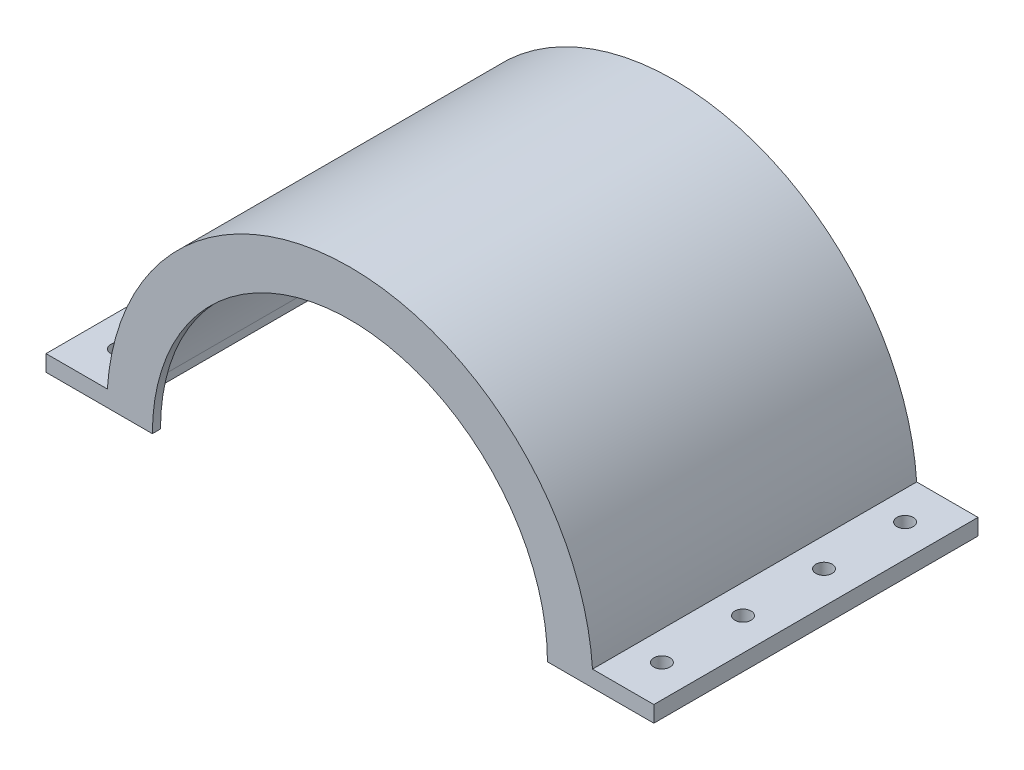
from build123d import *

# Parameters (mm, degrees)
BOSS_EXTRUDE1_DEPTH     = 80
SHELL1_T                = -2
SKETCH2_W               = 15.034493015
SKETCH2_H               = 76
SKETCH2_W_2             = 15.087666062
BOSS_EXTRUDE2_DEPTH     = 2
CUT_EXTRUDE1_REACH      = 82
CUT_EXTRUDE2_REACH      = 82
SKETCH6_R               = 2
CUT_EXTRUDE6_DEPTH      = 61
LPATTERN1_COUNT         = 4
LPATTERN1_PITCH         = 20
MIRROR1_COPY_1_SKETCH_R = 2
MIRROR1_COPY_1_DEPTH    = 61
MIRROR1_COPY_2_SKETCH_R = 2
MIRROR1_COPY_2_DEPTH    = 61
MIRROR1_COPY_3_SKETCH_R = 2
MIRROR1_COPY_3_DEPTH    = 61


with BuildPart() as part:
    # Sketch1 → Boss-Extrude1 (new body)
    with BuildSketch(Plane.XY):
        with BuildLine():
            Line((-75, 0), (75, 0))
            Line((75, 0), (75, 4))
            Line((75, 4), (59.866518188, 4))
            ThreePointArc((59.866518188, 4), (0, 60), (-59.866518188, 4))
            Line((-59.866518188, 4), (-75, 4))
            Line((-75, 4), (-75, 0))
        make_face()
    extrude(amount=BOSS_EXTRUDE1_DEPTH)

    # Shell1
    shell1_openings = [part.faces().sort_by_distance(p)[0] for p in [
        (0, 0, 40),
    ]]
    offset(amount=SHELL1_T, openings=shell1_openings, kind=Kind.INTERSECTION)

    # Sketch2 → Boss-Extrude2 (add)
    with BuildSketch(Plane.XZ.offset(-2)):
        with Locations((-65.482753492, 40)):
            Rectangle(SKETCH2_W, SKETCH2_H)
        with Locations((65.456166969, 40)):
            Rectangle(SKETCH2_W_2, SKETCH2_H)
    extrude(amount=BOSS_EXTRUDE2_DEPTH)

    # Sketch3 → Cut-Extrude1 (cut, up to next)
    with BuildSketch(Plane.XY.offset(80), mode=Mode.PRIVATE) as cut_extrude1_sk1:
        with BuildLine():
            Line((-48.75, 0), (48.75, 0))
            ThreePointArc((48.75, 0), (0, 48.75), (-48.75, 0))
        make_face()
    cut_extrude1_tool1 = extrude(cut_extrude1_sk1.sketch, amount=-CUT_EXTRUDE1_REACH, mode=Mode.PRIVATE) & part.part
    add(cut_extrude1_tool1.solids().sort_by_distance((0, 20.690143, 80))[0], mode=Mode.SUBTRACT)

    # Sketch5 → Cut-Extrude2 (cut, up to next)
    with BuildSketch(Plane(origin=(0, 0, 0), x_dir=(-1, 0, 0), z_dir=(0, 0, -1)), mode=Mode.PRIVATE) as cut_extrude2_sk1:
        with BuildLine():
            Line((-15, 0), (15, 0))
            ThreePointArc((15, 0), (0, 15), (-15, 0))
        make_face()
    cut_extrude2_tool1 = extrude(cut_extrude2_sk1.sketch, amount=-CUT_EXTRUDE2_REACH, mode=Mode.PRIVATE) & part.part
    add(cut_extrude2_tool1.solids().sort_by_distance((0, 6.366198, 0))[0], mode=Mode.SUBTRACT)

    # Sketch6 → Cut-Extrude6 (cut, through all)
    with BuildSketch(Plane.XZ):
        with Locations(Location((67, 70, 0), (0, 0, 270))):  # turned: the seam where the file's is
            Circle(SKETCH6_R)
    cut_extrude6 = extrude(amount=-CUT_EXTRUDE6_DEPTH, mode=Mode.SUBTRACT)

    # LPattern1: Cut-Extrude6 ×4
    with Locations(*[(0, 0, -i * LPATTERN1_PITCH) for i in range(1, LPATTERN1_COUNT)]):
        add(cut_extrude6, mode=Mode.SUBTRACT)

    # Mirror1: Cut-Extrude6 across plane
    add(cut_extrude6.mirror(Plane(origin=(0, 0, 0), x_dir=(0, 0, 1), z_dir=(1, 0, 0))), mode=Mode.SUBTRACT)

    # Mirror1 copy 1 sketch → Mirror1 copy 1 (cut, through all)
    with BuildSketch(Plane(origin=(0, 0, -20), x_dir=(-1, 0, 0), z_dir=(0, -1, 0))):
        with Locations((67, -70)):
            Circle(MIRROR1_COPY_1_SKETCH_R)
    extrude(amount=-MIRROR1_COPY_1_DEPTH, mode=Mode.SUBTRACT)

    # Mirror1 copy 2 sketch → Mirror1 copy 2 (cut, through all)
    with BuildSketch(Plane(origin=(0, 0, -40), x_dir=(-1, 0, 0), z_dir=(0, -1, 0))):
        with Locations((67, -70)):
            Circle(MIRROR1_COPY_2_SKETCH_R)
    extrude(amount=-MIRROR1_COPY_2_DEPTH, mode=Mode.SUBTRACT)

    # Mirror1 copy 3 sketch → Mirror1 copy 3 (cut, through all)
    with BuildSketch(Plane(origin=(0, 0, -60), x_dir=(-1, 0, 0), z_dir=(0, -1, 0))):
        with Locations((67, -70)):
            Circle(MIRROR1_COPY_3_SKETCH_R)
    extrude(amount=-MIRROR1_COPY_3_DEPTH, mode=Mode.SUBTRACT)


solid = part.part
